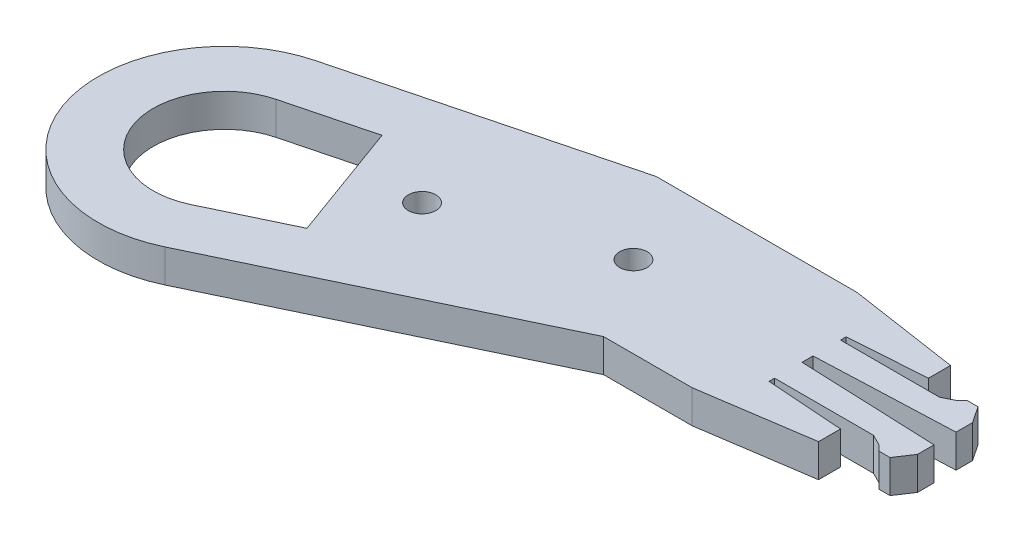
from build123d import *

# Parameters (mm, degrees)
SKETCH4_R           = 1.25
BOSS_EXTRUDE2_DEPTH = 3


with BuildPart() as part:
    # Sketch4 → Boss-Extrude2 (new body)
    with BuildSketch(Plane(origin=(0, 0, 0), x_dir=(1, 0, 0), z_dir=(0, 1, 0))):
        with BuildLine():
            Line((-2.879370047, 11.133697864), (21.737293787, 17.5))
            Line((21.737293787, 17.5), (40, 17.5))
            Line((40, 17.5), (50, 16))
            Line((50, 16), (50, 14))
            Line((50, 14), (43, 13.5))
            Line((43, 13.5), (43, 13))
            Line((43, 13), (52, 13))
            Line((52, 13), (53, 13.5))
            Line((53, 13.5), (53.5, 14))
            Line((53.5, 14), (54.5, 14))
            Line((54.5, 14), (55.5, 12.5))
            Line((55.5, 12.5), (55.5, 11))
            Line((55.5, 11), (43, 10.5))
            Line((43, 10.5), (43, 9.5))
            Line((43, 9.5), (55.5, 9))
            Line((55.5, 9), (55.5, 7.5))
            Line((55.5, 7.5), (54.5, 6))
            Line((54.5, 6), (53.5, 6))
            Line((53.5, 6), (53, 6.5))
            Line((53, 6.5), (52, 7))
            Line((52, 7), (43, 7))
            Line((43, 7), (43, 6.5))
            Line((43, 6.5), (50, 6))
            Line((50, 6), (50, 4))
            Line((50, 4), (40, 2.5))
            Line((40, 2.5), (31.953794717, 2.5))
            Line((31.953794717, 2.5), (4.950877613, -10.37973077))
            ThreePointArc((4.950877613, -10.37973077), (-10.806465139, -3.933231648), (-2.879370047, 11.133697864))
        make_face()
        with Locations((13.155696691, 4.788282007)):
            Circle(SKETCH4_R, mode=Mode.SUBTRACT)
        with Locations((27.251086003, 9.918584156)):
            Circle(SKETCH4_R, mode=Mode.SUBTRACT)
        with BuildLine():
            Line((6.033902904, 8.274325422), (9.94087165, -2.459982986))
            Line((9.94087165, -2.459982986), (2.798322129, -5.866804348))
            ThreePointArc((2.798322129, -5.866804348), (-6.108002035, -2.223130932), (-1.627470026, 6.292959662))
            Line((-1.627470026, 6.292959662), (6.033902904, 8.274325422))
        make_face(mode=Mode.SUBTRACT)
    extrude(amount=-BOSS_EXTRUDE2_DEPTH)


solid = part.part
